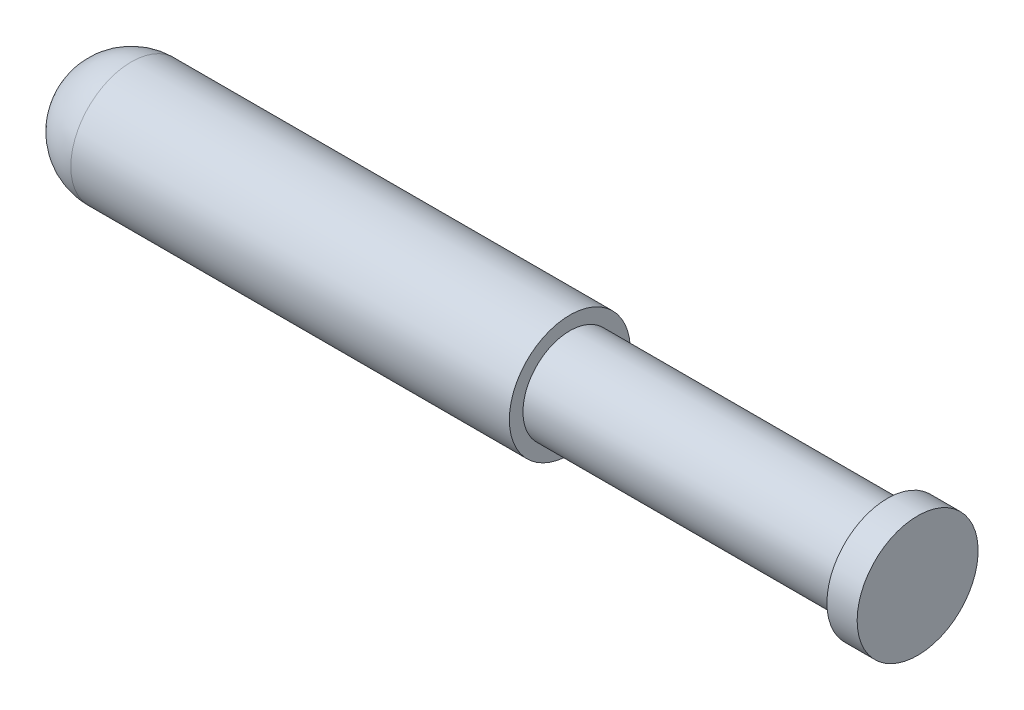
from build123d import *

# Parameters (mm, degrees)
FILLET1_R = 4


with BuildPart() as part:
    # Sketch1 → Revolve1 (revolve)
    with BuildSketch(Plane.XY, mode=Mode.PRIVATE) as revolve1_sk:
        Polygon((0, 0), (0, 4), (33, 4), (33, 3.1), (54, 3.1), (54, 4), (56, 4), (56, 0), align=None)
    revolve(revolve1_sk.sketch.rotate(Axis((0, 0, 0), (1, 0, 0)), 90), axis=Axis((0, 0, 0), (1, 0, 0)))  # turned: the seam where the file's is

    # Fillet1
    fillet1_edges = [part.edges().sort_by_distance(p)[0] for p in [
        (0, 0, -4),
    ]]
    fillet(fillet1_edges, radius=FILLET1_R)


solid = part.part
